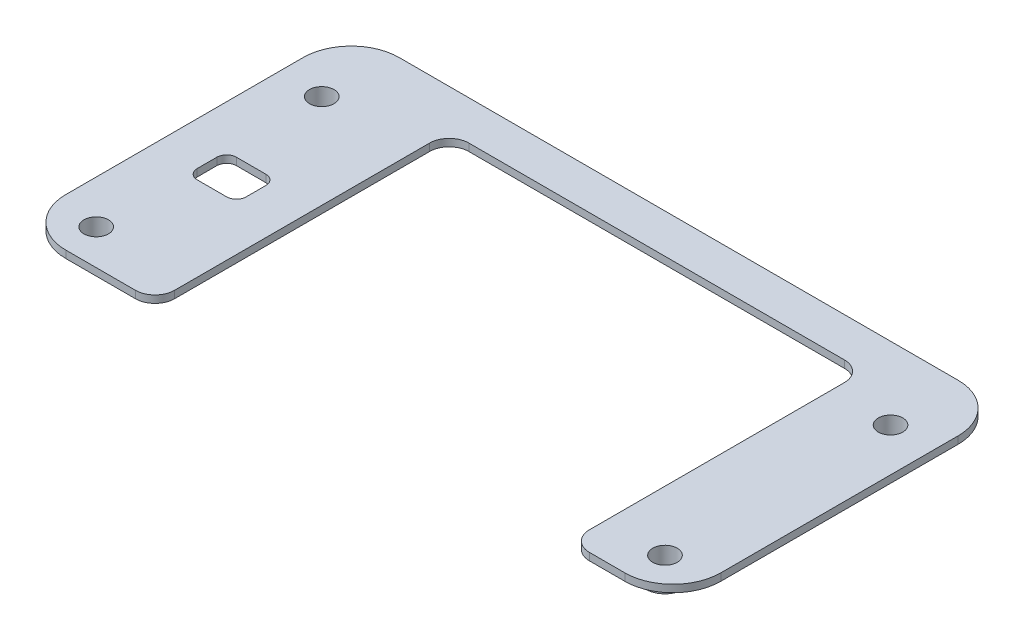
from build123d import *

# Parameters (mm, degrees)
EXTRUDE_1_DEPTH     = 0.75
SKETCH_2_R          = 2
EXTRUDE_2_DEPTH     = 1.25
SKETCH_3_R          = 1.25
CUT_EXTRUDE_1_DEPTH = 3
SKETCH_4_W          = 42.3
SKETCH_4_H          = 30
CUT_EXTRUDE_2_DEPTH = 3
FILLET_1_R          = 2
CUT_EXTRUDE_3_DEPTH = 1.75


with BuildPart() as part:
    # 草图1 → 凸台-拉伸1 (new body)
    with BuildSketch(Plane(origin=(0, 0, 0), x_dir=(1, 0, 0), z_dir=(0, 1, 0))):
        with BuildLine():
            Line((-28.283443195, 18.335), (28.716556805, 18.335))
            ThreePointArc((28.716556805, 18.335), (32.181380033, 16.899823228), (33.616556805, 13.435))
            Line((33.616556805, 13.435), (33.616556805, -10.765))
            ThreePointArc((33.616556805, -10.765), (32.181380033, -14.229823228), (28.716556805, -15.665))
            Line((28.716556805, -15.665), (20.216556805, -15.665))
            Line((20.216556805, -15.665), (-19.783443195, -15.665))
            Line((-19.783443195, -15.665), (-28.283443195, -15.665))
            ThreePointArc((-28.283443195, -15.665), (-31.748266423, -14.229823228), (-33.183443195, -10.765))
            Line((-33.183443195, -10.765), (-33.183443195, 13.435))
            ThreePointArc((-33.183443195, 13.435), (-31.748266423, 16.899823228), (-28.283443195, 18.335))
        make_face()
    extrude(amount=EXTRUDE_1_DEPTH)

    # 草图2 → 凸台-拉伸2 (add)
    with BuildSketch(Plane.XZ):
        with Locations((-28.783443195, 12.065)):
            Circle(SKETCH_2_R)
        with Locations((-28.783443195, -10.935)):
            Circle(SKETCH_2_R)
        with Locations((29.216556805, 12.065)):
            Circle(SKETCH_2_R)
        with Locations((29.216556805, -10.935)):
            Circle(SKETCH_2_R)
    extrude(amount=EXTRUDE_2_DEPTH)

    # 草图3 → 切除-拉伸1 (cut, through all)
    with BuildSketch(Plane.XZ.offset(1.25)):
        with Locations((-28.783443195, 12.065)):
            Circle(SKETCH_3_R)
        with Locations((-28.783443195, -10.935)):
            Circle(SKETCH_3_R)
        with Locations((29.216556805, -10.935)):
            Circle(SKETCH_3_R)
        with Locations((29.216556805, 12.065)):
            Circle(SKETCH_3_R)
    extrude(amount=-CUT_EXTRUDE_1_DEPTH, mode=Mode.SUBTRACT)

    # 草图4 → 切除-拉伸2 (cut, through all)
    with BuildSketch(Plane(origin=(0, 0.75, 0), x_dir=(1, 0, 0), z_dir=(0, 1, 0))):
        with Locations((1.966556805, -0.665)):
            Rectangle(SKETCH_4_W, SKETCH_4_H)
    extrude(amount=-CUT_EXTRUDE_2_DEPTH, mode=Mode.SUBTRACT)

    # 圆角1
    fillet_1_edges = [part.edges().sort_by_distance(p)[0] for p in [
        (-19.183443195, 0.375, 15.665),
        (-19.183443195, 0.375, -14.335),
        (23.116556805, 0.375, -14.335),
        (23.116556805, 0.375, 15.665),
    ]]
    fillet(fillet_1_edges, radius=FILLET_1_R)

    # 草图6 → 切除-拉伸3 (cut, through all)
    with BuildSketch(Plane.XZ):
        with BuildLine():
            Line((-27.783443195, 2.765), (-24.783443195, 2.765))
            ThreePointArc((-24.783443195, 2.765), (-24.076336414, 2.472106781), (-23.783443195, 1.765))
            Line((-23.783443195, 1.765), (-23.783443195, -0.235))
            ThreePointArc((-23.783443195, -0.235), (-24.076336414, -0.942106781), (-24.783443195, -1.235))
            Line((-24.783443195, -1.235), (-27.783443195, -1.235))
            ThreePointArc((-27.783443195, -1.235), (-28.490549976, -0.942106781), (-28.783443195, -0.235))
            Line((-28.783443195, -0.235), (-28.783443195, 1.765))
            ThreePointArc((-28.783443195, 1.765), (-28.490549976, 2.472106781), (-27.783443195, 2.765))
        make_face()
    extrude(amount=-CUT_EXTRUDE_3_DEPTH, mode=Mode.SUBTRACT)


solid = part.part
